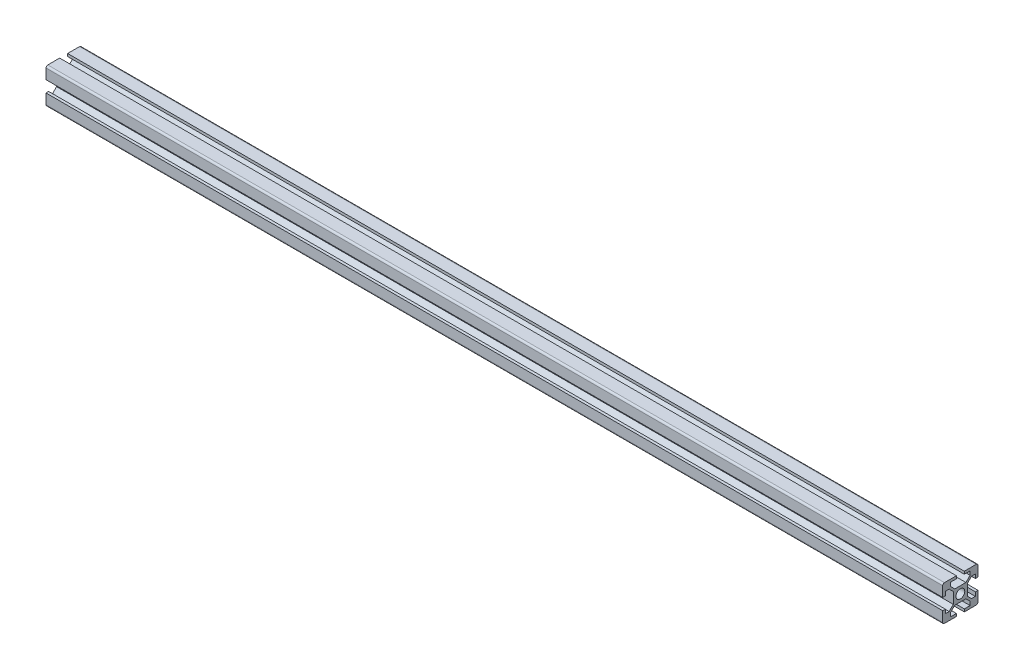
from build123d import *

# Parameters (mm, degrees)
SKETCH_1_R            = 2.5
F_20_X_20_X_2_2_DEPTH = 508


with BuildPart() as part:
    # 草图1 → 铝型材 20 X 20 X 2(2) (new body)
    with BuildSketch(Plane(origin=(0, 0, 0), x_dir=(0, 0, -1), z_dir=(1, 0, 0))):
        with BuildLine():
            Line((-10, 9), (-10, 3.25))
            Line((-10, 3.25), (-8.5, 3.25))
            Line((-8.5, 3.25), (-8.5, 5.5))
            Line((-8.5, 5.5), (-6.348528137, 5.5))
            Line((-6.348528137, 5.5), (-4, 3.151471863))
            Line((-4, 3.151471863), (-4, -3.151471863))
            Line((-4, -3.151471863), (-6.348528137, -5.5))
            Line((-6.348528137, -5.5), (-8.5, -5.5))
            Line((-8.5, -5.5), (-8.5, -3.25))
            Line((-8.5, -3.25), (-10, -3.25))
            Line((-10, -3.25), (-10, -9))
            ThreePointArc((-10, -9), (-9.707106781, -9.707106781), (-9, -10))
            Line((-9, -10), (-2.25, -10))
            Line((-2.25, -10), (-2.25, -8.5))
            Line((-2.25, -8.5), (-5.5, -8.5))
            Line((-5.5, -8.5), (-5.5, -6.348528137))
            Line((-5.5, -6.348528137), (-3.151471863, -4))
            Line((-3.151471863, -4), (3.151471863, -4))
            Line((3.151471863, -4), (5.5, -6.348528137))
            Line((5.5, -6.348528137), (5.5, -8.5))
            Line((5.5, -8.5), (2.25, -8.5))
            Line((2.25, -8.5), (2.25, -10))
            Line((2.25, -10), (9, -10))
            ThreePointArc((9, -10), (9.707106781, -9.707106781), (10, -9))
            Line((10, -9), (10, -3.25))
            Line((10, -3.25), (8.5, -3.25))
            Line((8.5, -3.25), (8.5, -5.5))
            Line((8.5, -5.5), (6.348528137, -5.5))
            Line((6.348528137, -5.5), (4, -3.151471863))
            Line((4, -3.151471863), (4, 3.151471863))
            Line((4, 3.151471863), (6.348528137, 5.5))
            Line((6.348528137, 5.5), (8.5, 5.5))
            Line((8.5, 5.5), (8.5, 3.25))
            Line((8.5, 3.25), (10, 3.25))
            Line((10, 3.25), (10, 9))
            ThreePointArc((10, 9), (9.707106781, 9.707106781), (9, 10))
            Line((9, 10), (2.25, 10))
            Line((2.25, 10), (2.25, 8.5))
            Line((2.25, 8.5), (5.5, 8.5))
            Line((5.5, 8.5), (5.5, 6.348528137))
            Line((5.5, 6.348528137), (3.151471863, 4))
            Line((3.151471863, 4), (-3.151471863, 4))
            Line((-3.151471863, 4), (-5.5, 6.348528137))
            Line((-5.5, 6.348528137), (-5.5, 8.5))
            Line((-5.5, 8.5), (-2.25, 8.5))
            Line((-2.25, 8.5), (-2.25, 10))
            Line((-2.25, 10), (-9, 10))
            ThreePointArc((-9, 10), (-9.707106781, 9.707106781), (-10, 9))
        make_face()
        Circle(SKETCH_1_R, mode=Mode.SUBTRACT)
    extrude(amount=F_20_X_20_X_2_2_DEPTH)


solid = part.part
